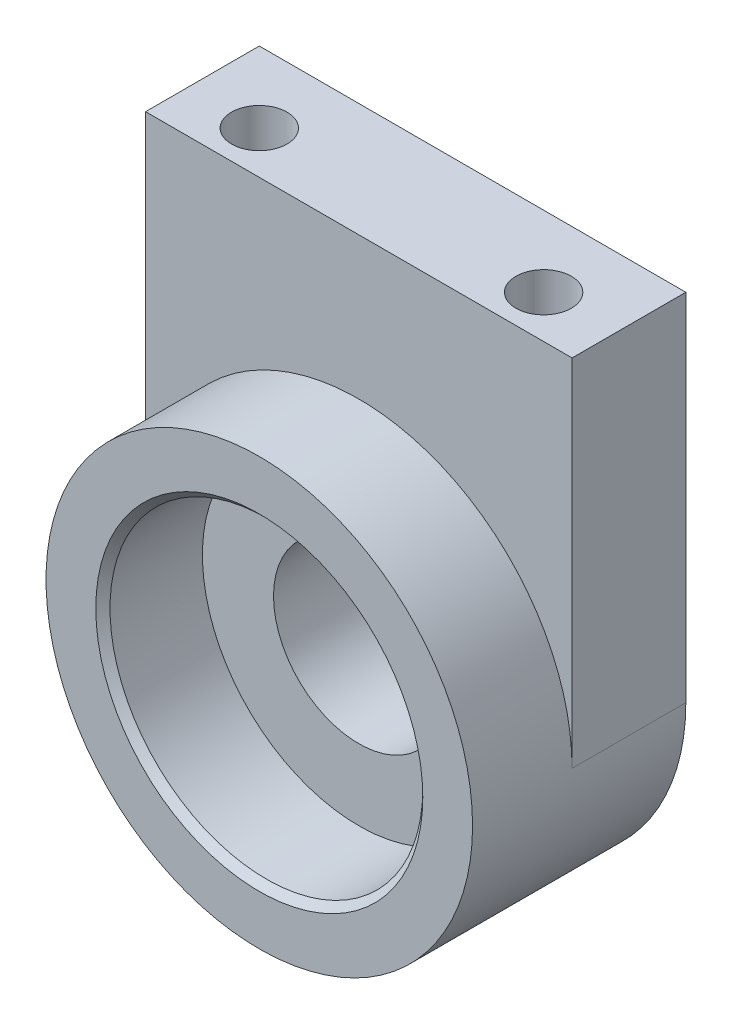
from build123d import *

# Parameters (mm, degrees)
SKETCH1_R           = 15
SKETCH1_R_2         = 11
BOSS_EXTRUDE1_DEPTH = 7
BOSS_EXTRUDE2_START = 8
BOSS_EXTRUDE2_DEPTH = 8
SKETCH4_R           = 1.95
CUT_EXTRUDE1_DEPTH  = 6
SKETCH5_R           = 6
CUT_EXTRUDE2_DEPTH  = 8
CHAMFER1_SIZE       = 0.5


with BuildPart() as part:
    # Sketch1 → Boss-Extrude1 (new body)
    with BuildSketch(Plane.XY):
        Circle(SKETCH1_R)
        Circle(SKETCH1_R_2, mode=Mode.SUBTRACT)
    extrude(amount=BOSS_EXTRUDE1_DEPTH)

    # Sketch3 → Boss-Extrude2 (add)
    with BuildSketch(Plane(origin=(0, 0, 0), x_dir=(-1, 0, 0), z_dir=(0, 0, -1)).offset(BOSS_EXTRUDE2_START)):
        with BuildLine():
            Line((-15, 0), (-15, 25))
            Line((-15, 25), (15, 25))
            Line((15, 25), (15, 0))
            ThreePointArc((15, 0), (0, -15), (-15, 0))
        make_face()
    extrude(amount=-BOSS_EXTRUDE2_DEPTH)

    # Sketch4 → Cut-Extrude1 (cut)
    with BuildSketch(Plane(origin=(0, 25, 0), x_dir=(1, 0, 0), z_dir=(0, 1, 0))):
        with Locations(Location((-10, 3, 0), (0, 0, 270))):
            Circle(SKETCH4_R)
        with Locations(Location((10, 3, 0), (0, 0, 270))):
            Circle(SKETCH4_R)
    extrude(amount=-CUT_EXTRUDE1_DEPTH, mode=Mode.SUBTRACT)

    # Sketch5 → Cut-Extrude2 (cut)
    with BuildSketch(Plane.XY):
        Circle(SKETCH5_R)
    extrude(amount=-CUT_EXTRUDE2_DEPTH, mode=Mode.SUBTRACT)

    # Chamfer1
    chamfer1_edges = [part.edges().sort_by_distance(p)[0] for p in [
        (-11, 0, 7),
    ]]
    chamfer(chamfer1_edges, length=CHAMFER1_SIZE)


solid = part.part
